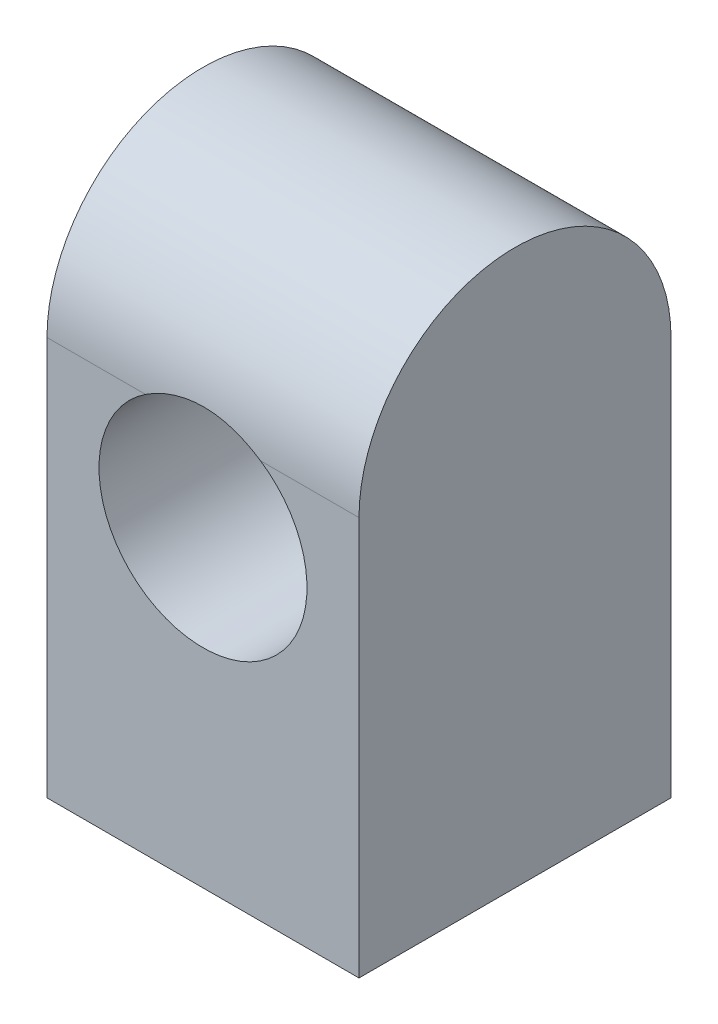
from build123d import *

# Parameters (mm, degrees)
BOSS_EXTRUDE1_DEPTH             = 18
SKETCH2_R                       = 6
CUT_EXTRUDE1_DEPTH              = 19
M4X0_7_TAPPED_HOLE2_D           = 3.3
M4X0_7_TAPPED_HOLE2_DEPTH       = 10.1
M4X0_7_TAPPED_HOLE2_CSINK_D     = 4.05
M4X0_7_TAPPED_HOLE2_CSINK_ANGLE = 90
M4X0_7_TAPPED_HOLE2_TIP         = 0.991420021


with BuildPart() as part:
    # Sketch1 → Boss-Extrude1 (new body)
    with BuildSketch(Plane(origin=(0, 0, 0), x_dir=(0, 0, -1), z_dir=(1, 0, 0))):
        with BuildLine():
            Line((-10, 17.13989977), (-10, -5.86010023))
            Line((-10, -5.86010023), (8, -5.86010023))
            Line((8, -5.86010023), (8, 17.13989977))
            ThreePointArc((8, 17.13989977), (-1, 26.13989977), (-10, 17.13989977))
        make_face()
    extrude(amount=BOSS_EXTRUDE1_DEPTH)

    # Sketch2 → Cut-Extrude1 (cut, through all)
    with BuildSketch(Plane.XY.offset(10)):
        with Locations(Location((9, 12.13989977, 0), (0, 0, 56.442690238))):  # turned: the seam where the file's is
            Circle(SKETCH2_R)
    extrude(amount=-CUT_EXTRUDE1_DEPTH, mode=Mode.SUBTRACT)

    # M4x0.7 Tapped Hole2
    with Locations(Plane(origin=(0, -5.86010023, 0), x_dir=(-1, 0, 0), z_dir=(0, -1, 0))):
        with Locations((-5, -5.601078957), (-5, 2.398921043), (-13, 2.398921043), (-13, -5.601078957)):
            CounterSinkHole(M4X0_7_TAPPED_HOLE2_D / 2, M4X0_7_TAPPED_HOLE2_CSINK_D / 2, depth=M4X0_7_TAPPED_HOLE2_DEPTH, counter_sink_angle=M4X0_7_TAPPED_HOLE2_CSINK_ANGLE)
            with Locations((0, 0, -(M4X0_7_TAPPED_HOLE2_DEPTH + M4X0_7_TAPPED_HOLE2_TIP / 2))):  # 118° drill point
                Cone(0, M4X0_7_TAPPED_HOLE2_D / 2, M4X0_7_TAPPED_HOLE2_TIP, mode=Mode.SUBTRACT)


solid = part.part
